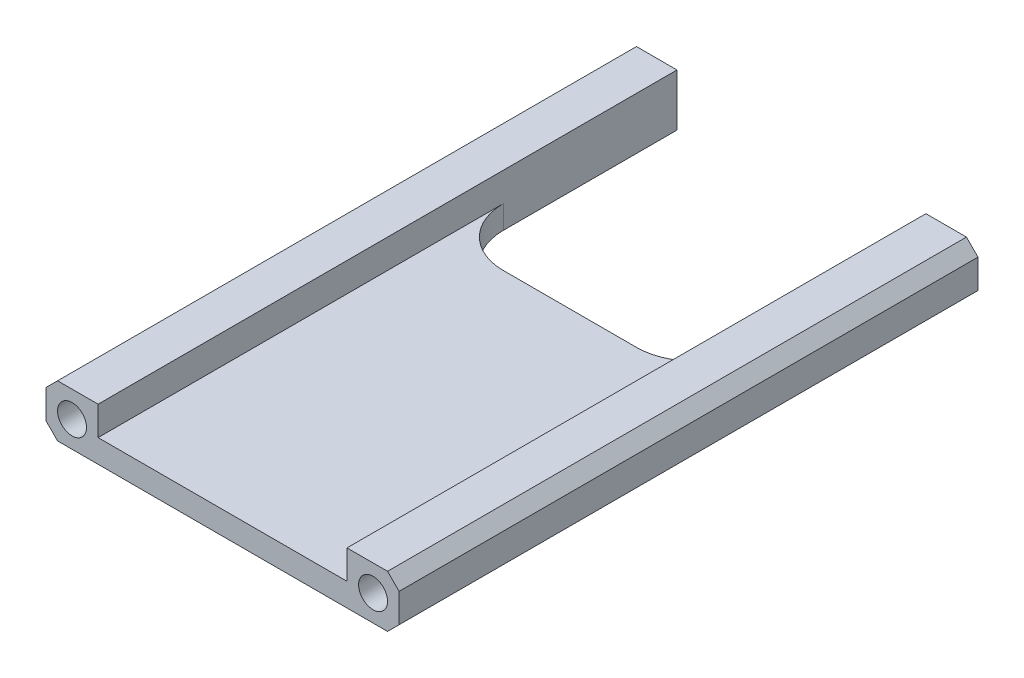
from build123d import *

# Parameters (mm, degrees)
SKETCH1_W           = 77.47
SKETCH1_H           = 127
BOSS_EXTRUDE1_DEPTH = 11.43
SKETCH2_R           = 3.175
CUT_EXTRUDE1_DEPTH  = 128
CUT_EXTRUDE2_DEPTH  = 12.43
SKETCH4_W           = 54.61
SKETCH4_H           = 6.35
CUT_EXTRUDE3_DEPTH  = 128
CHAMFER1_SIZE       = 2.54


with BuildPart() as part:
    # Sketch1 → Boss-Extrude1 (new body)
    with BuildSketch(Plane(origin=(0, 0, 0), x_dir=(1, 0, 0), z_dir=(0, 1, 0))):
        with Locations((38.735, 63.5)):
            Rectangle(SKETCH1_W, SKETCH1_H)
    extrude(amount=BOSS_EXTRUDE1_DEPTH)

    # Sketch2 → Cut-Extrude1 (cut, through all)
    with BuildSketch(Plane.XY):
        with Locations((5.715, 5.715)):
            Circle(SKETCH2_R)
        with Locations((71.755, 5.715)):
            Circle(SKETCH2_R)
    extrude(amount=-CUT_EXTRUDE1_DEPTH, mode=Mode.SUBTRACT)

    # Sketch3 → Cut-Extrude2 (cut, through all)
    with BuildSketch(Plane(origin=(0, 11.43, 0), x_dir=(1, 0, 0), z_dir=(0, 1, 0))):
        with BuildLine():
            Line((11.43, 127), (11.43, 88.9))
            ThreePointArc((11.43, 88.9), (15.149743879, 79.919743879), (24.13, 76.2))
            Line((24.13, 76.2), (53.34, 76.2))
            ThreePointArc((53.34, 76.2), (62.320256121, 79.919743879), (66.04, 88.9))
            Line((66.04, 88.9), (66.04, 127))
            Line((66.04, 127), (11.43, 127))
        make_face()
    extrude(amount=-CUT_EXTRUDE2_DEPTH, mode=Mode.SUBTRACT)

    # Sketch4 → Cut-Extrude3 (cut, through all)
    with BuildSketch(Plane(origin=(0, 0, -127), x_dir=(-1, 0, 0), z_dir=(0, 0, -1))):
        with Locations((-38.735, 8.255)):
            Rectangle(SKETCH4_W, SKETCH4_H)
    extrude(amount=-CUT_EXTRUDE3_DEPTH, mode=Mode.SUBTRACT)

    # Chamfer1
    chamfer1_edges = [part.edges().sort_by_distance(p)[0] for p in [
        (77.47, 11.43, -63.5),
        (0, 11.43, -63.5),
        (77.47, 0, -63.5),
        (0, 0, -63.5),
    ]]
    chamfer(chamfer1_edges, length=CHAMFER1_SIZE)


solid = part.part
